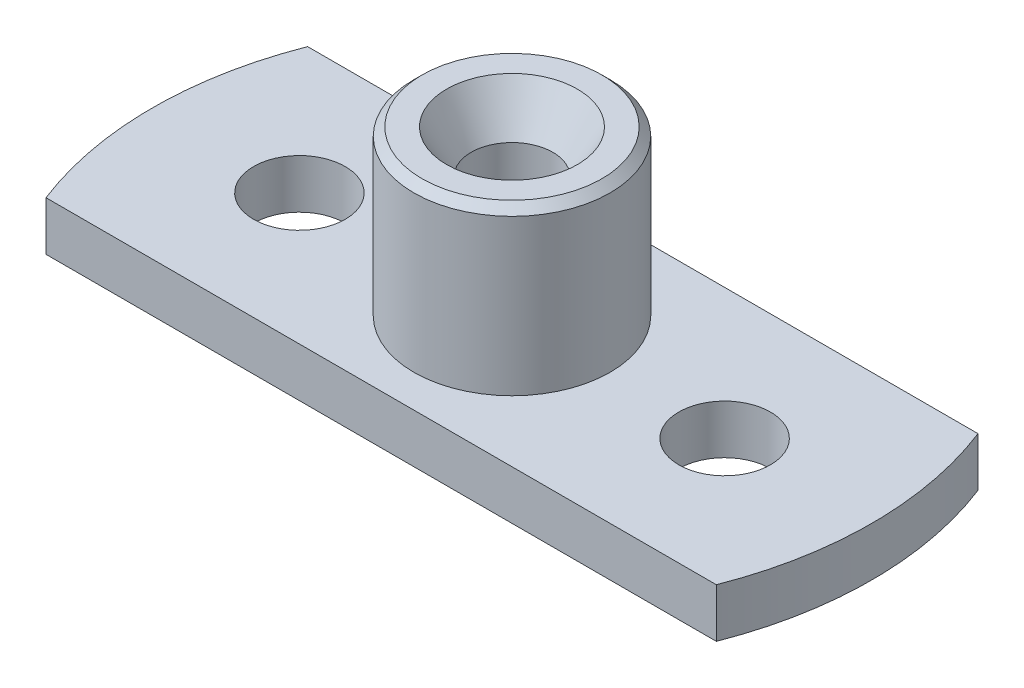
from build123d import *

# Parameters (mm, degrees)
BASE_SKETCH_W                   = 20.493901532
BASE_SKETCH_H                   = 8
BASE_EXTRUDE_DEPTH              = 1.5
PROTRUSION_START                = 1.5
PROTRUSION_SKETCH_R             = 3
PROTRUSION_EXTRUDE_DEPTH        = 5
F_2_8_2_8_DIAMETER_HOLE1_D      = 2.8
PROTRUSION_CHAMFER_SIZE         = 0.25
F_2_5MM_DOWEL_HOLE3_D           = 2.5
F_2_5MM_DOWEL_HOLE3_DEPTH       = 6.5
F_2_5MM_DOWEL_HOLE3_CSINK_D     = 4
F_2_5MM_DOWEL_HOLE3_CSINK_ANGLE = 60
F_5MM_CIRCLE_SKETCH_R           = 2.5
F_5MM_DIAMETER_CUT_DEPTH        = 0.7


with BuildPart() as part:
    # Base Sketch → Base Extrude (new body)
    with BuildSketch(Plane(origin=(0, 0, 0), x_dir=(1, 0, 0), z_dir=(0, 1, 0))):
        with BuildLine():
            Line((-10.246950766, -4), (-10.246950766, 4))
            ThreePointArc((-10.246950766, 4), (-11, 0), (-10.246950766, -4))
        make_face()
        Rectangle(BASE_SKETCH_W, BASE_SKETCH_H)
        with BuildLine():
            Line((10.246950766, -4), (10.246950766, 4))
            ThreePointArc((10.246950766, 4), (11, 0), (10.246950766, -4))
        make_face()
    extrude(amount=BASE_EXTRUDE_DEPTH)

    # Protrusion Sketch → Protrusion Extrude (add)
    with BuildSketch(Plane(origin=(0, 0, 0), x_dir=(1, 0, 0), z_dir=(0, 1, 0)).offset(PROTRUSION_START)):
        Circle(PROTRUSION_SKETCH_R)
    extrude(amount=PROTRUSION_EXTRUDE_DEPTH)

    # Ø2.8 (2.8) Diameter Hole1 (through all)
    with Locations(Plane(origin=(0, 1.5, 0), x_dir=(1, 0, 0), z_dir=(0, 1, 0))):
        with Locations((-6.5, 0), (6.5, 0)):
            Hole(F_2_8_2_8_DIAMETER_HOLE1_D / 2)

    # Protrusion Chamfer
    protrusion_chamfer_edges = [part.edges().sort_by_distance(p)[0] for p in [
        (-3, 6.5, 0),
    ]]
    chamfer(protrusion_chamfer_edges, length=PROTRUSION_CHAMFER_SIZE)

    # Ø2.5mm Dowel Hole3
    with Locations(Plane(origin=(0, 6.5, 0), x_dir=(1, 0, 0), z_dir=(0, 1, 0))):
        with Locations((0, 0)):
            CounterSinkHole(F_2_5MM_DOWEL_HOLE3_D / 2, F_2_5MM_DOWEL_HOLE3_CSINK_D / 2, depth=F_2_5MM_DOWEL_HOLE3_DEPTH, counter_sink_angle=F_2_5MM_DOWEL_HOLE3_CSINK_ANGLE)

    # 5mm Circle Sketch → 5mm Diameter Cut (cut)
    with BuildSketch(Plane(origin=(0, 0, 0), x_dir=(1, 0, 0), z_dir=(0, 1, 0))):
        Circle(F_5MM_CIRCLE_SKETCH_R)
    extrude(amount=F_5MM_DIAMETER_CUT_DEPTH, mode=Mode.SUBTRACT)


solid = part.part
